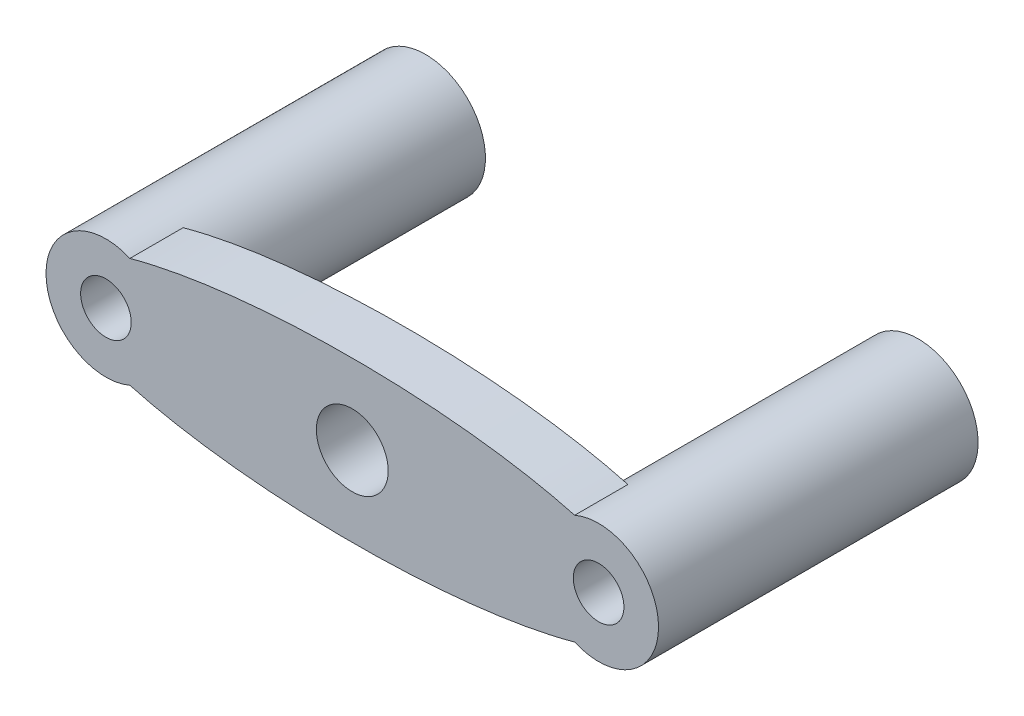
from build123d import *

# Parameters (mm, degrees)
SKETCH1_R           = 2.413
SKETCH1_R_2         = 3.429
BOSS_EXTRUDE1_DEPTH = 5.08
SKETCH2_R           = 5.715
SKETCH2_R_2         = 2.413
BOSS_EXTRUDE2_DEPTH = 25.4


with BuildPart() as part:
    # Sketch1 → Boss-Extrude1 (new body)
    with BuildSketch(Plane.XY):
        with BuildLine():
            ThreePointArc((21.211318458, -5.238895267), (29.21, 0), (21.211318458, 5.238895267))
            add(Edge.make_bspline(
                [(21.211318458, 5.238895267), (0, 11.083329031), (-21.211318458, 5.238895267)],
                knots=[3.899659671, 3.899659671, 3.899659671, 5.525118289, 5.525118289, 5.525118289], degree=2, weights=[1, 0.687519064, 1]))
            ThreePointArc((-21.211318458, 5.238895267), (-29.21, 0), (-21.211318458, -5.238895267))
            add(Edge.make_bspline(
                [(-21.211318458, -5.238895267), (0, -11.083329031), (21.211318458, -5.238895267)],
                knots=[0.758067018, 0.758067018, 0.758067018, 2.383525636, 2.383525636, 2.383525636], degree=2, weights=[1, 0.687519064, 1]))
        make_face()
        with Locations((-23.495, 0)):
            Circle(SKETCH1_R, mode=Mode.SUBTRACT)
        Circle(SKETCH1_R_2, mode=Mode.SUBTRACT)
        with Locations((23.495, 0)):
            Circle(SKETCH1_R, mode=Mode.SUBTRACT)
    extrude(amount=BOSS_EXTRUDE1_DEPTH)

    # Sketch2 → Boss-Extrude2 (add)
    with BuildSketch(Plane(origin=(0, 0, 0), x_dir=(-1, 0, 0), z_dir=(0, 0, -1))):
        with Locations((-23.495, 0)):
            Circle(SKETCH2_R)
        with Locations((-23.495, 0)):
            Circle(SKETCH2_R_2, mode=Mode.SUBTRACT)
        with Locations((23.495, 0)):
            Circle(SKETCH2_R)
        with Locations((23.495, 0)):
            Circle(SKETCH2_R_2, mode=Mode.SUBTRACT)
    extrude(amount=BOSS_EXTRUDE2_DEPTH)


solid = part.part
